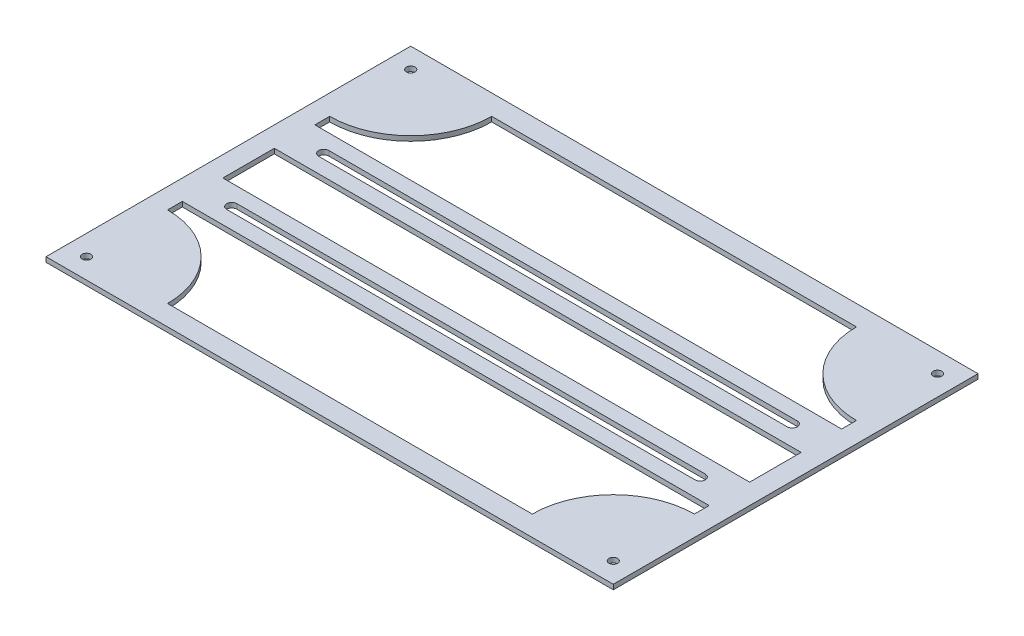
from build123d import *

# Parameters (mm, degrees)
SKETCH1_W             = 177.8
SKETCH1_H             = 114.3
SKETCH1_W_2           = 165.1
SKETCH1_H_2           = 16.134929366
BOSS_EXTRUDE1_DEPTH   = 1.524
CUT_EXTRUDE1_DEPTH    = 2.524
F_6_32_TAPPED_HOLE1_D = 2.7051
F_6_32_TAPPED_HOLE2_D = 2.7051


with BuildPart() as part:
    # Sketch1 → Boss-Extrude1 (new body)
    with BuildSketch(Plane(origin=(0, 0, 0), x_dir=(1, 0, 0), z_dir=(0, 1, 0))):
        Rectangle(SKETCH1_W, SKETCH1_H)
        with BuildLine():
            Line((-82.55, -25.4), (-82.55, -20.767464683))
            Line((-82.55, -20.767464683), (82.55, -20.767464683))
            Line((82.55, -20.767464683), (82.55, -25.4))
            ThreePointArc((82.55, -25.4), (64.589487758, -32.839487758), (57.15, -50.8))
            Line((57.15, -50.8), (-57.15, -50.8))
            ThreePointArc((-57.15, -50.8), (-64.589487758, -32.839487758), (-82.55, -25.4))
        make_face(mode=Mode.SUBTRACT)
        Rectangle(SKETCH1_W_2, SKETCH1_H_2, mode=Mode.SUBTRACT)
        with BuildLine():
            Line((82.55, 20.767464683), (-82.55, 20.767464683))
            Line((-82.55, 20.767464683), (-82.55, 25.4))
            ThreePointArc((-82.55, 25.4), (-64.589487758, 32.839487758), (-57.15, 50.8))
            Line((-57.15, 50.8), (57.15, 50.8))
            ThreePointArc((57.15, 50.8), (64.589487758, 32.839487758), (82.55, 25.4))
            Line((82.55, 25.4), (82.55, 20.767464683))
        make_face(mode=Mode.SUBTRACT)
    extrude(amount=BOSS_EXTRUDE1_DEPTH)

    # Sketch3 → Cut-Extrude1 (cut, through all)
    with BuildSketch(Plane(origin=(0, 1.524, 0), x_dir=(1, 0, 0), z_dir=(0, 1, 0))):
        with BuildLine():
            Line((-73.406, 16.004964683), (73.406, 16.004964683))
            ThreePointArc((73.406, 16.004964683), (74.9935, 14.417464683), (73.406, 12.829964683))
            Line((73.406, 12.829964683), (-73.406, 12.829964683))
            ThreePointArc((-73.406, 12.829964683), (-74.9935, 14.417464683), (-73.406, 16.004964683))
        make_face()
        with BuildLine():
            Line((-73.406, -16.004964683), (73.406, -16.004964683))
            ThreePointArc((73.406, -16.004964683), (74.9935, -14.417464683), (73.406, -12.829964683))
            Line((73.406, -12.829964683), (-73.406, -12.829964683))
            ThreePointArc((-73.406, -12.829964683), (-74.9935, -14.417464683), (-73.406, -16.004964683))
        make_face()
    extrude(amount=-CUT_EXTRUDE1_DEPTH, mode=Mode.SUBTRACT)

    # #6-32 Tapped Hole1 (through all)
    with Locations(Plane(origin=(0, 7.8105, 0), x_dir=(-1, 0, 0), z_dir=(0, 1, 0))):
        with Locations((82.55, -50.8), (82.55, 50.8), (-82.55, 50.8), (-82.55, -50.8)):
            Hole(F_6_32_TAPPED_HOLE1_D / 2)

    # #6-32 Tapped Hole2 (through all)
    with Locations(Plane(origin=(0, 1.524, 0), x_dir=(-1, 0, 0), z_dir=(0, 1, 0))):
        with Locations((82.55, -50.8), (82.55, 50.8), (-82.55, 50.8), (-82.55, -50.8)):
            Hole(F_6_32_TAPPED_HOLE2_D / 2)


solid = part.part
